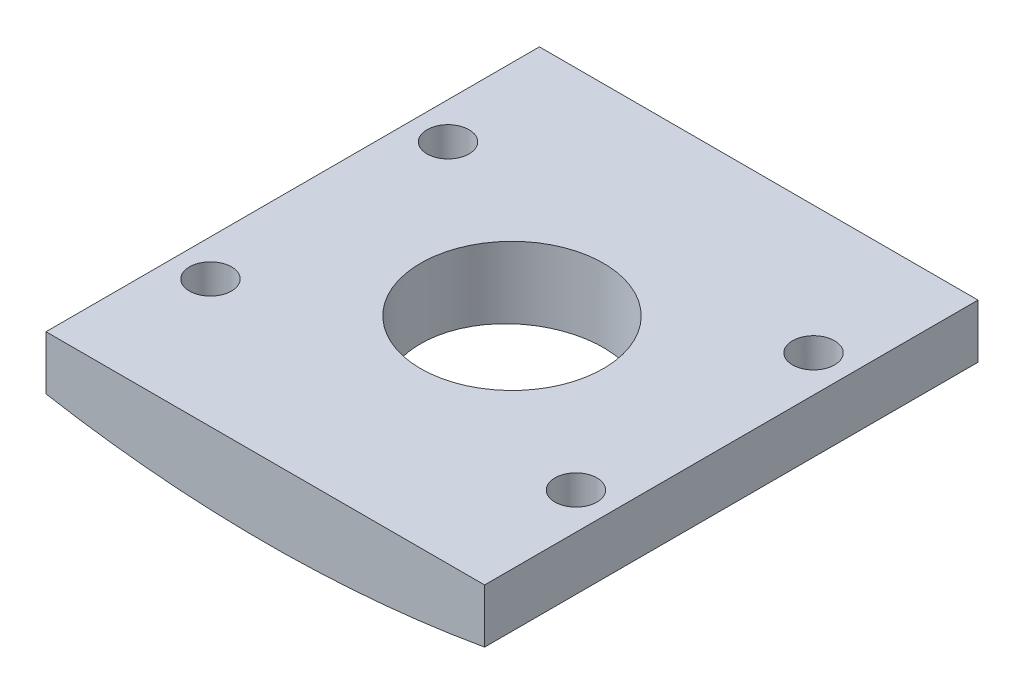
from build123d import *

# Parameters (mm, degrees)
SKETCH4_W                = 24
SKETCH4_H                = 27
BOSS_EXTRUDE3_DEPTH      = 3
BOSS_EXTRUDE3_DEPTH_BACK = 8
SKETCH5_W                = 28.405044576
SKETCH5_H                = 3.736732925
SKETCH6_R                = 5
CUT_EXTRUDE1_DEPTH       = 4
CUT_EXTRUDE1_DEPTH_BACK  = 8
SKETCH7_W                = 24
SKETCH7_H                = 27
CUT_EXTRUDE2_DEPTH       = 6
SKETCH8_R                = 1.15
CUT_EXTRUDE3_DEPTH       = 5.0000001
CUT_EXTRUDE4_START       = -2
SKETCH9_R                = 1.9
CUT_EXTRUDE4_DEPTH       = 2


with BuildPart() as part:
    # Sketch4 → Boss-Extrude3 (new body, two sides)
    with BuildSketch(Plane(origin=(0, 0, 0), x_dir=(1, 0, 0), z_dir=(0, 1, 0))) as boss_extrude3_sk:
        Rectangle(SKETCH4_W, SKETCH4_H)
    extrude(amount=BOSS_EXTRUDE3_DEPTH)
    extrude(boss_extrude3_sk.sketch, amount=-BOSS_EXTRUDE3_DEPTH_BACK)

    # Sketch5 → Cut-Revolve1 (revolve, cut)
    with BuildSketch(Plane(origin=(0, 0, 0), x_dir=(0, 0, -1), z_dir=(1, 0, 0))):
        with Locations((0.702522288, -8.868366462)):
            Rectangle(SKETCH5_W, SKETCH5_H)
    revolve(axis=Axis((0, 62, 13.5), (0, 0, -1)), mode=Mode.SUBTRACT)

    # Sketch6 → Cut-Extrude1 (cut, two sides)
    with BuildSketch(Plane(origin=(0, 0, 0), x_dir=(1, 0, 0), z_dir=(0, 1, 0))) as cut_extrude1_sk:
        Circle(SKETCH6_R)
    extrude(amount=CUT_EXTRUDE1_DEPTH, mode=Mode.SUBTRACT)
    extrude(cut_extrude1_sk.sketch, amount=-CUT_EXTRUDE1_DEPTH_BACK, mode=Mode.SUBTRACT)

    # Sketch7 → Cut-Extrude2 (cut)
    with BuildSketch(Plane(origin=(0, 3, 0), x_dir=(1, 0, 0), z_dir=(0, 1, 0))):
        Rectangle(SKETCH7_W, SKETCH7_H)
    extrude(amount=-CUT_EXTRUDE2_DEPTH, mode=Mode.SUBTRACT)

    # Sketch8 → Cut-Extrude3 (cut, through all)
    with BuildSketch(Plane(origin=(0, -3, 0), x_dir=(1, 0, 0), z_dir=(0, 1, 0))):
        with Locations((-10, 6.5)):
            Circle(SKETCH8_R)
        with Locations((-10, -6.5)):
            Circle(SKETCH8_R)
        with Locations((10, -6.5)):
            Circle(SKETCH8_R)
        with Locations((10, 6.5)):
            Circle(SKETCH8_R)
    extrude(amount=-CUT_EXTRUDE3_DEPTH, mode=Mode.SUBTRACT)

    # Sketch9 → Cut-Extrude4 (cut)
    with BuildSketch(Plane(origin=(0, -3, 0), x_dir=(1, 0, 0), z_dir=(0, 1, 0)).offset(CUT_EXTRUDE4_START)):
        with Locations((-10, 6.5)):
            Circle(SKETCH9_R)
        with Locations((-10, -6.5)):
            Circle(SKETCH9_R)
        with Locations((10, -6.5)):
            Circle(SKETCH9_R)
        with Locations((10, 6.5)):
            Circle(SKETCH9_R)
    extrude(amount=-CUT_EXTRUDE4_DEPTH, mode=Mode.SUBTRACT)


solid = part.part
